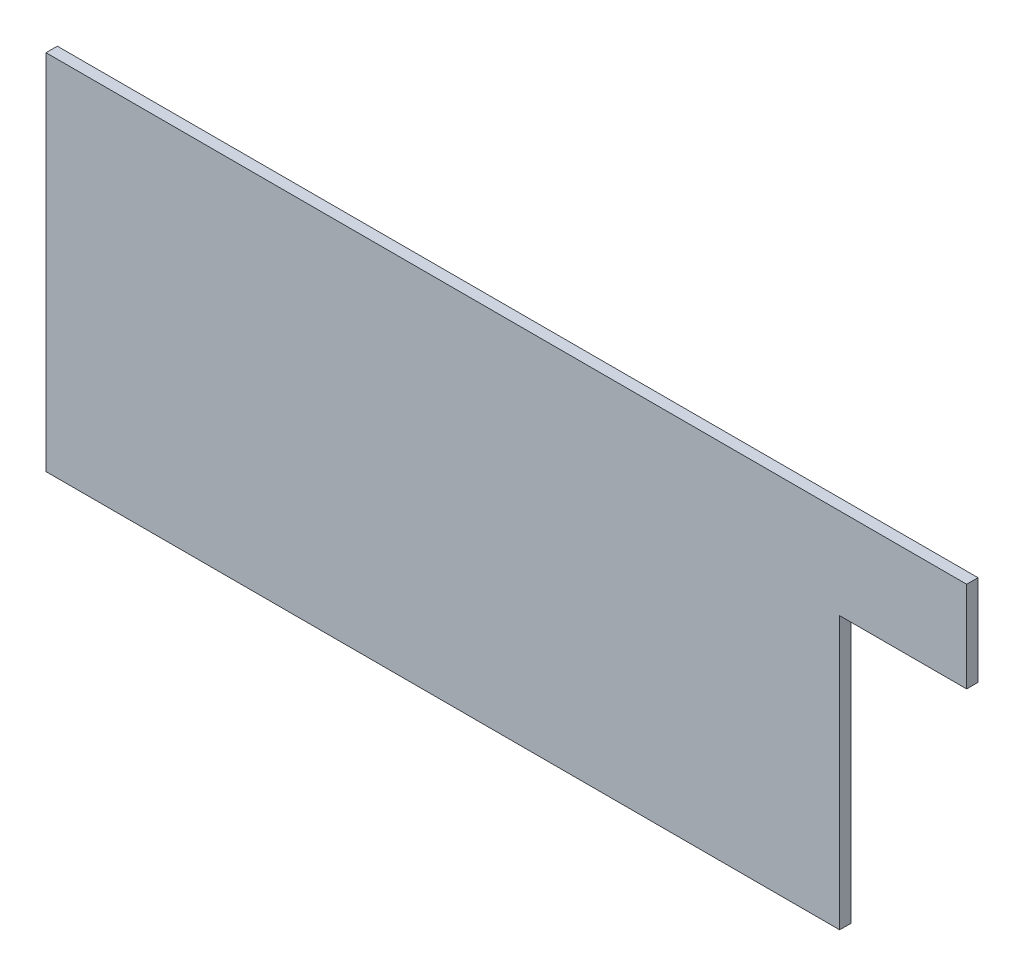
from build123d import *

# Parameters (mm, degrees)
BOSS_EXTRUDE1_DEPTH = 3.175


with BuildPart() as part:
    # Sketch1 → Boss-Extrude1 (new body)
    with BuildSketch(Plane.XY):
        Polygon((257.81, 76.2), (222.25, 76.2), (222.25, 0), (0, 0), (0, 101.6), (63.5, 101.6), (165.1, 101.6), (257.81, 101.6), align=None)
    extrude(amount=BOSS_EXTRUDE1_DEPTH)


solid = part.part
